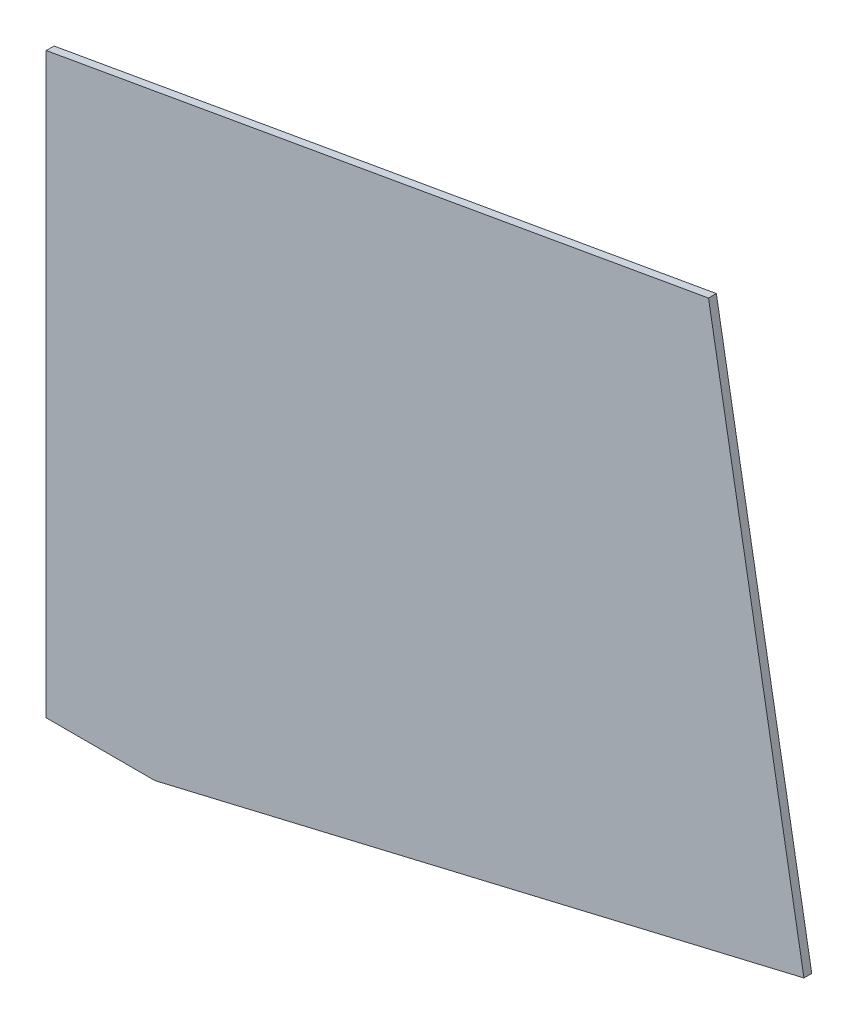
from build123d import *

# Parameters (mm, degrees)
BOSS_EXTRUDE1_DEPTH = 2.3622


with BuildPart() as part:
    # Sketch2 → Boss-Extrude1 (new body)
    with BuildSketch(Plane.XY):
        Polygon((228.94411819, 46.400546974), (32.8676, 0), (0, 0), (0, 174.625), (200.112935412, 209.910309702), align=None)
    extrude(amount=BOSS_EXTRUDE1_DEPTH)


solid = part.part
